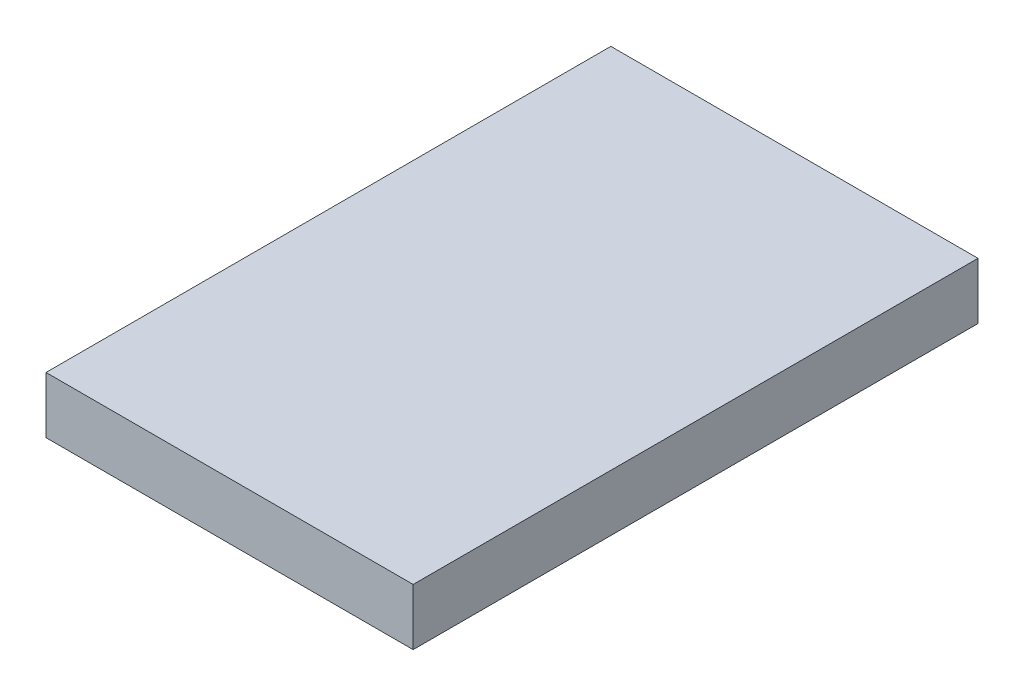
from build123d import *

# Parameters (mm, degrees)
SKETCH1_W           = 26
SKETCH1_H           = 40
BOSS_EXTRUDE1_DEPTH = 4


with BuildPart() as part:
    # Sketch1 → Boss-Extrude1 (new body)
    with BuildSketch(Plane(origin=(0, 0, 0), x_dir=(1, 0, 0), z_dir=(0, 1, 0))):
        Rectangle(SKETCH1_W, SKETCH1_H)
    extrude(amount=BOSS_EXTRUDE1_DEPTH)


solid = part.part
